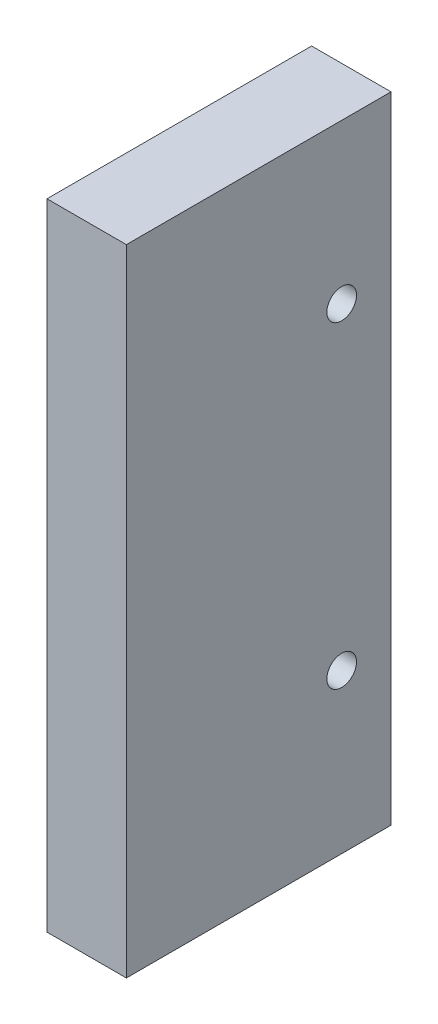
from build123d import *

# Parameters (mm, degrees)
SKETCH1_W           = 9.525
SKETCH1_H           = 76.2
BOSS_EXTRUDE1_DEPTH = 31.75
SKETCH2_R           = 1.778
CUT_EXTRUDE1_DEPTH  = 10.525
SKETCH3_R           = 1.7272
CUT_EXTRUDE2_DEPTH  = 19.05


with BuildPart() as part:
    # Sketch1 → Boss-Extrude1 (new body)
    with BuildSketch(Plane.XY):
        with Locations((4.7625, 38.1)):
            Rectangle(SKETCH1_W, SKETCH1_H)
    extrude(amount=BOSS_EXTRUDE1_DEPTH)

    # Sketch2 → Cut-Extrude1 (cut, through all)
    with BuildSketch(Plane.ZY):
        with Locations((5.9182, 57.15)):
            Circle(SKETCH2_R)
        with Locations((5.9182, 19.05)):
            Circle(SKETCH2_R)
    extrude(amount=-CUT_EXTRUDE1_DEPTH, mode=Mode.SUBTRACT)

    # Sketch3 → Cut-Extrude2 (cut)
    with BuildSketch(Plane.XZ):
        with Locations((4.7625, 25.4)):
            Circle(SKETCH3_R)
        with Locations((4.7625, 12.7)):
            Circle(SKETCH3_R)
    extrude(amount=-CUT_EXTRUDE2_DEPTH, mode=Mode.SUBTRACT)


solid = part.part
